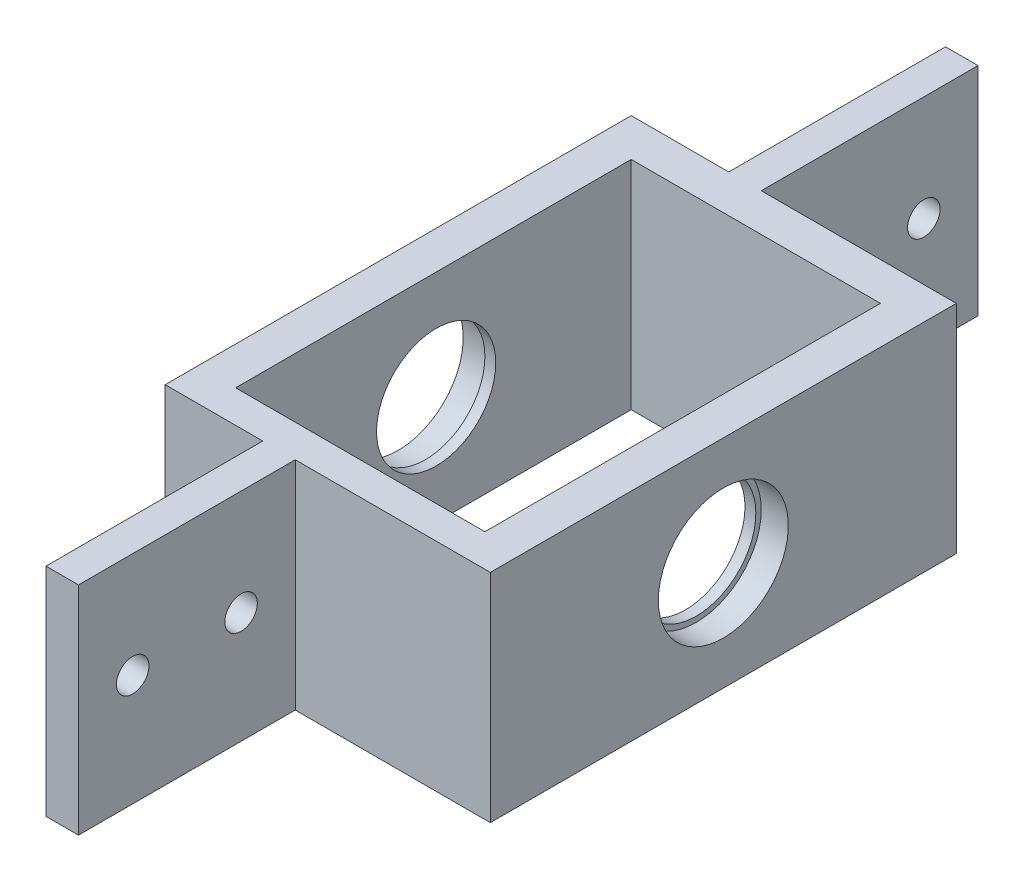
from build123d import *

# Parameters (mm, degrees)
SKETCH_1_W          = 30
SKETCH_1_H          = 20
EXTRUDE_1_DEPTH     = 3
EXTRUDE_2_DEPTH     = 40
SKETCH_1_4_W        = 3.5
SKETCH_1_4_H        = 20
EXTRUDE_3_DEPTH     = 40
SKETCH_3_R          = 6
CUT_EXTRUDE_2_DEPTH = 38
SKETCH_4_R          = 6
SKETCH_4_R_2        = 5.5
EXTRUDE_4_DEPTH     = 1
SKETCH_5_R          = 6
SKETCH_5_R_2        = 5.5
EXTRUDE_5_DEPTH     = 1
SKETCH_7_W          = 3.5
SKETCH_7_H          = 20
EXTRUDE_6_DEPTH     = 23
SKETCH_9_W          = 20
SKETCH_9_H          = 20
SKETCH_9_R          = 1.5
EXTRUDE_7_DEPTH     = 3


with BuildPart() as part:
    # Sketch 1 → Extrude 1 (new body)
    with BuildSketch(Plane.XY):
        with Locations((-68, -0.145751311)):
            Rectangle(SKETCH_1_W, SKETCH_1_H)
    extrude(amount=EXTRUDE_1_DEPTH)

    # Sketch 1_3 → Extrude 2 (add)
    with BuildSketch(Plane.XY):
        Polygon((-56.5, 9.854248689), (-56.5, -10.145751311), (-53, -10.145751311), (-53, -0.145751311), (-53, 9.854248689), align=None)
    extrude(amount=-EXTRUDE_2_DEPTH)

    # Sketch 1_4 → Extrude 3 (add)
    with BuildSketch(Plane.XY):
        with Locations((-81.25, -0.145751311)):
            Rectangle(SKETCH_1_4_W, SKETCH_1_4_H)
    extrude(amount=-EXTRUDE_3_DEPTH)

    # Sketch 3 → Cut-Extrude 2 (cut)
    with BuildSketch(Plane.ZY.offset(83)):
        with Locations((-18.5, -0.145751311)):
            Circle(SKETCH_3_R)
    extrude(amount=-CUT_EXTRUDE_2_DEPTH, mode=Mode.SUBTRACT)

    # Sketch 4 → Extrude 4 (add)
    with BuildSketch(Plane(origin=(-56.5, 0, 0), x_dir=(0, 0, -1), z_dir=(1, 0, 0))):
        with Locations((18.5, -0.145751311)):
            Circle(SKETCH_4_R)
        with Locations((18.5, -0.145751311)):
            Circle(SKETCH_4_R_2, mode=Mode.SUBTRACT)
    extrude(amount=EXTRUDE_4_DEPTH)

    # Sketch 5 → Extrude 5 (add)
    with BuildSketch(Plane(origin=(-79.5, 0, 0), x_dir=(0, 0, -1), z_dir=(1, 0, 0))):
        with Locations((18.5, -0.145751311)):
            Circle(SKETCH_5_R)
        with Locations((18.5, -0.145751311)):
            Circle(SKETCH_5_R_2, mode=Mode.SUBTRACT)
    extrude(amount=-EXTRUDE_5_DEPTH)

    # Sketch 7 → Extrude 6 (add)
    with BuildSketch(Plane(origin=(-79.5, 0, 0), x_dir=(0, 0, -1), z_dir=(1, 0, 0))):
        with Locations((38.25, -0.145751311)):
            Rectangle(SKETCH_7_W, SKETCH_7_H)
    extrude(amount=EXTRUDE_6_DEPTH)

    # Sketch 9 → Extrude 7 (add)
    with BuildSketch(Plane.ZY.offset(71)):
        with Locations((-50, -0.145751311)):
            Rectangle(SKETCH_9_W, SKETCH_9_H)
        with Locations((-55, 0.144248689)):
            Circle(SKETCH_9_R, mode=Mode.SUBTRACT)
        with Locations((-45, 0.144248689)):
            Circle(SKETCH_9_R, mode=Mode.SUBTRACT)
    extrude_7 = extrude(amount=EXTRUDE_7_DEPTH)

    # Mirror 1: Extrude 7 across plane
    add(extrude_7.mirror(Plane.XY.offset(-18.5)))


solid = part.part
